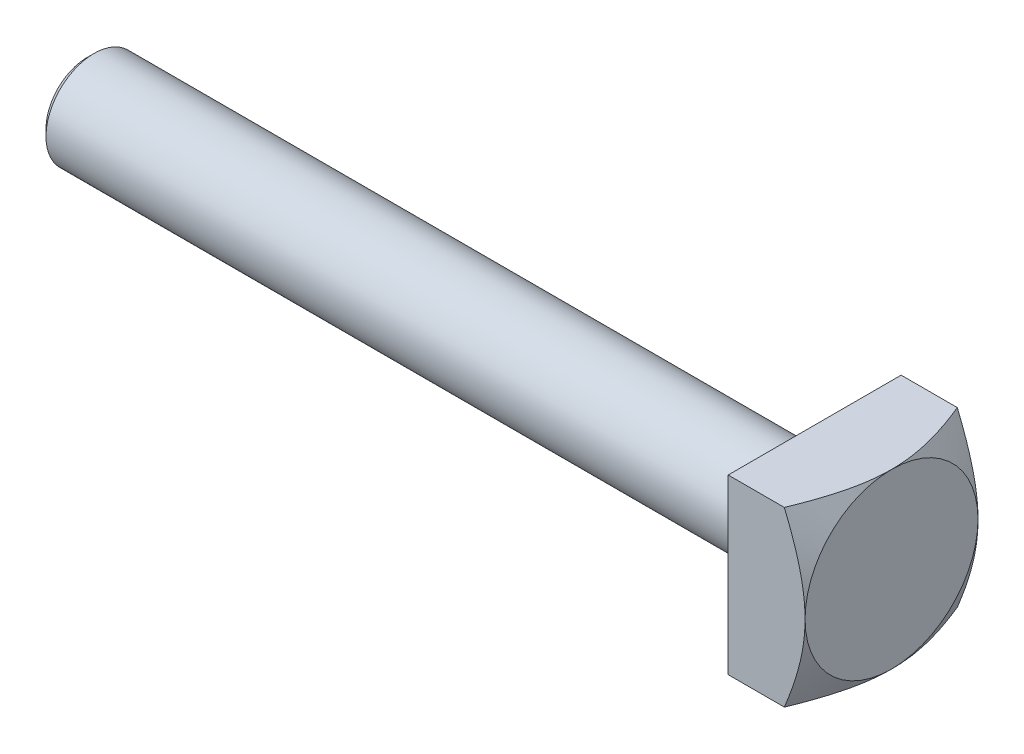
from build123d import *

# Parameters (mm, degrees)
SKETCH4_W           = 18
SKETCH4_H           = 18
BOSS_EXTRUDE1_DEPTH = 8
SKETCH5_OUTSIDE_W   = 72.14
SKETCH5_OUTSIDE_H   = 72.14
SKETCH5_OUTSIDE_R   = 9
CUT_EXTRUDE3_DEPTH  = 10
CUT_EXTRUDE3_TAPER  = 60


with BuildPart() as part:
    # Sketch1 → Revolve1 (revolve)
    with BuildSketch(Plane.XY):
        Polygon((-33.667489974, 5), (-34.374596755, 4.292893219), (-34.374596755, 0), (41.332510026, 0), (41.332510026, 5), align=None)
    revolve(axis=Axis((-59.973351377, 0, 0), (1, 0, 0)))

    # Sketch4 → Boss-Extrude1 (add)
    with BuildSketch(Plane(origin=(41.332510026, 0, 0), x_dir=(0, 0, -1), z_dir=(1, 0, 0))):
        Rectangle(SKETCH4_W, SKETCH4_H)
    extrude(amount=BOSS_EXTRUDE1_DEPTH)

    # Sketch5 outside → Cut-Extrude3 (cut)
    with BuildSketch(Plane(origin=(49.332510026, 0, 0), x_dir=(0, 0, -1), z_dir=(1, 0, 0))):
        Rectangle(SKETCH5_OUTSIDE_W, SKETCH5_OUTSIDE_H)
        Circle(SKETCH5_OUTSIDE_R, mode=Mode.SUBTRACT)
    extrude(amount=-CUT_EXTRUDE3_DEPTH, taper=CUT_EXTRUDE3_TAPER, mode=Mode.SUBTRACT)


solid = part.part
